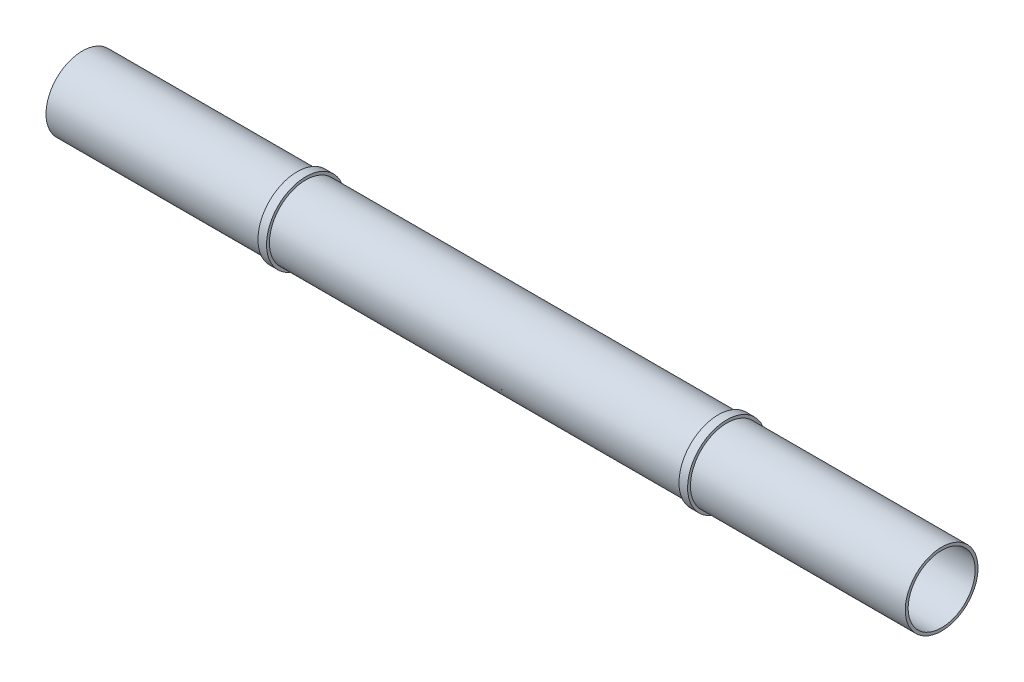
from build123d import *

# Parameters (mm, degrees)
SKETCH3_R               = 11.7
CUT_EXTRUDE1_DEPTH      = 1
CUT_EXTRUDE1_DEPTH_BACK = 301


with BuildPart() as part:
    # Sketch1 → Revolve1 (revolve)
    with BuildSketch(Plane.XY):
        Polygon((-150, 0), (150, 0), (150, 12.7), (75, 12.7), (75, 13.7), (72, 13.7), (72, 12.7), (-72, 12.7), (-72, 13.7), (-75, 13.7), (-75, 12.7), (-150, 12.7), align=None)
    revolve(axis=Axis((-150, 0, 0), (1, 0, 0)))

    # Sketch3 → Cut-Extrude1 (cut, two sides)
    with BuildSketch(Plane(origin=(150, 0, 0), x_dir=(0, 0, -1), z_dir=(1, 0, 0))) as cut_extrude1_sk:
        Circle(SKETCH3_R)
    extrude(amount=CUT_EXTRUDE1_DEPTH, mode=Mode.SUBTRACT)
    extrude(cut_extrude1_sk.sketch, amount=-CUT_EXTRUDE1_DEPTH_BACK, mode=Mode.SUBTRACT)


solid = part.part
